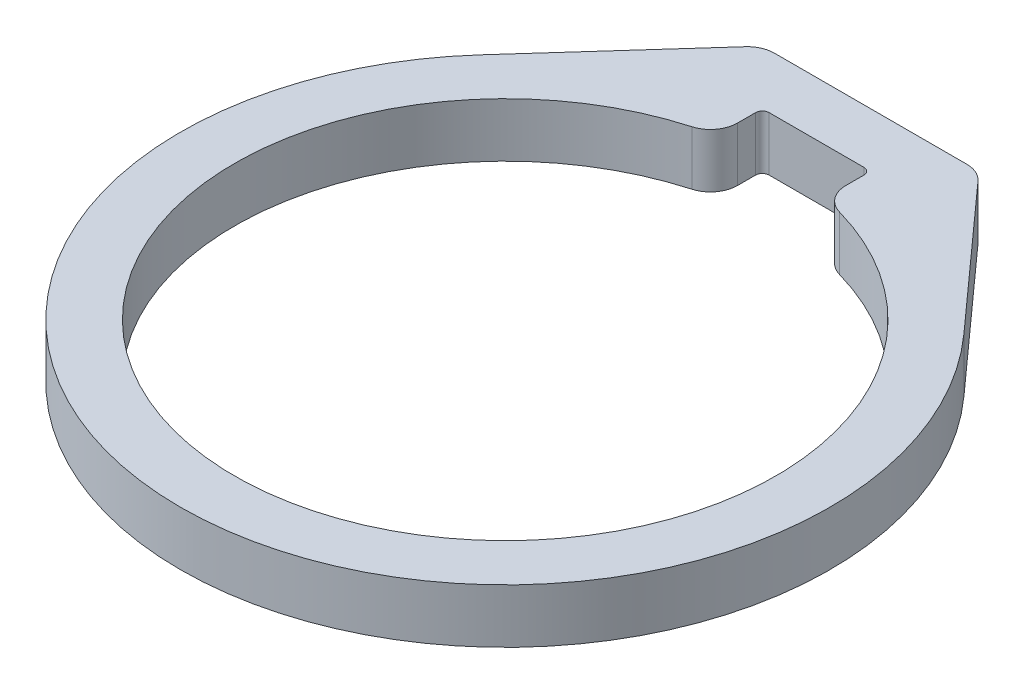
from build123d import *

# Parameters (mm, degrees)
BOSS_EXTRUDE1_DEPTH = 6.35
FILLET1_R           = 0.79375
FILLET3_R           = 3.175


with BuildPart() as part:
    # Sketch1 → Boss-Extrude1 (new body)
    with BuildSketch(Plane(origin=(0, 0, 0), x_dir=(1, 0, 0), z_dir=(0, 1, 0))):
        with BuildLine():
            Line((-12.7, 42.8625), (-28.334044467, 25.471394232))
            ThreePointArc((-28.334044467, 25.471394232), (0, -38.1), (28.334044467, 25.471394232))
            Line((28.334044467, 25.471394232), (12.7, 42.8625))
            Line((12.7, 42.8625), (-12.7, 42.8625))
        make_face()
        with BuildLine():
            Line((-6.35, 36.5125), (6.35, 36.5125))
            Line((6.35, 36.5125), (6.35, 31.108519733))
            ThreePointArc((6.35, 31.108519733), (0, -31.75), (-6.35, 31.108519733))
            Line((-6.35, 31.108519733), (-6.35, 36.5125))
        make_face(mode=Mode.SUBTRACT)
    extrude(amount=BOSS_EXTRUDE1_DEPTH)

    # Fillet1
    fillet1_edges = [part.edges().sort_by_distance(p)[0] for p in [
        (-6.35, 3.175, -36.5125),
        (6.35, 3.175, -36.5125),
    ]]
    fillet(fillet1_edges, radius=FILLET1_R)

    # Fillet3
    fillet3_edges = [part.edges().sort_by_distance(p)[0] for p in [
        (-6.35, 3.175, -31.108519733),
        (6.35, 3.175, -31.108519733),
        (-12.7, 3.175, -42.8625),
        (12.7, 3.175, -42.8625),
    ]]
    fillet(fillet3_edges, radius=FILLET3_R)


solid = part.part
